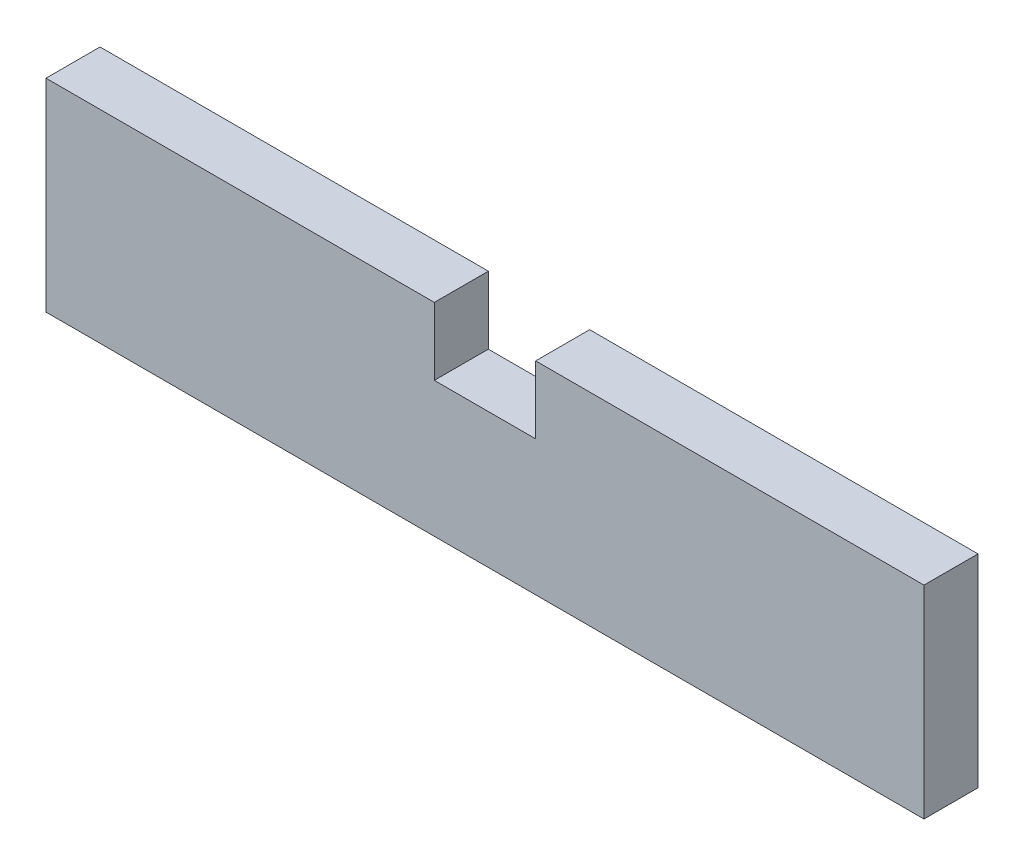
from build123d import *

# Parameters (mm, degrees)
SKIZZE1_W                       = 65
SKIZZE1_H                       = 15
AUFSATZ_LINEAR_AUSTRAGEN1_DEPTH = 4
SCHNITT_LINEAR_AUSTRAGEN1_REACH = 6
SKIZZE2_W                       = 7.5
SKIZZE2_H                       = 5


with BuildPart() as part:
    # Skizze1 → Aufsatz-Linear austragen1 (new body)
    with BuildSketch(Plane.XY):
        with Locations((32.5, 7.5)):
            Rectangle(SKIZZE1_W, SKIZZE1_H)
    extrude(amount=AUFSATZ_LINEAR_AUSTRAGEN1_DEPTH)

    # Skizze2 → Schnitt-Linear austragen1 (cut, up to next)
    with BuildSketch(Plane.XY.offset(4), mode=Mode.PRIVATE) as schnitt_linear_austragen1_sk1:
        with Locations((32.5, 12.5)):
            Rectangle(SKIZZE2_W, SKIZZE2_H)
    schnitt_linear_austragen1_tool1 = extrude(schnitt_linear_austragen1_sk1.sketch, amount=-SCHNITT_LINEAR_AUSTRAGEN1_REACH, mode=Mode.PRIVATE) & part.part
    add(schnitt_linear_austragen1_tool1.solids().sort_by_distance((32.5, 12.5, 4))[0], mode=Mode.SUBTRACT)


solid = part.part
